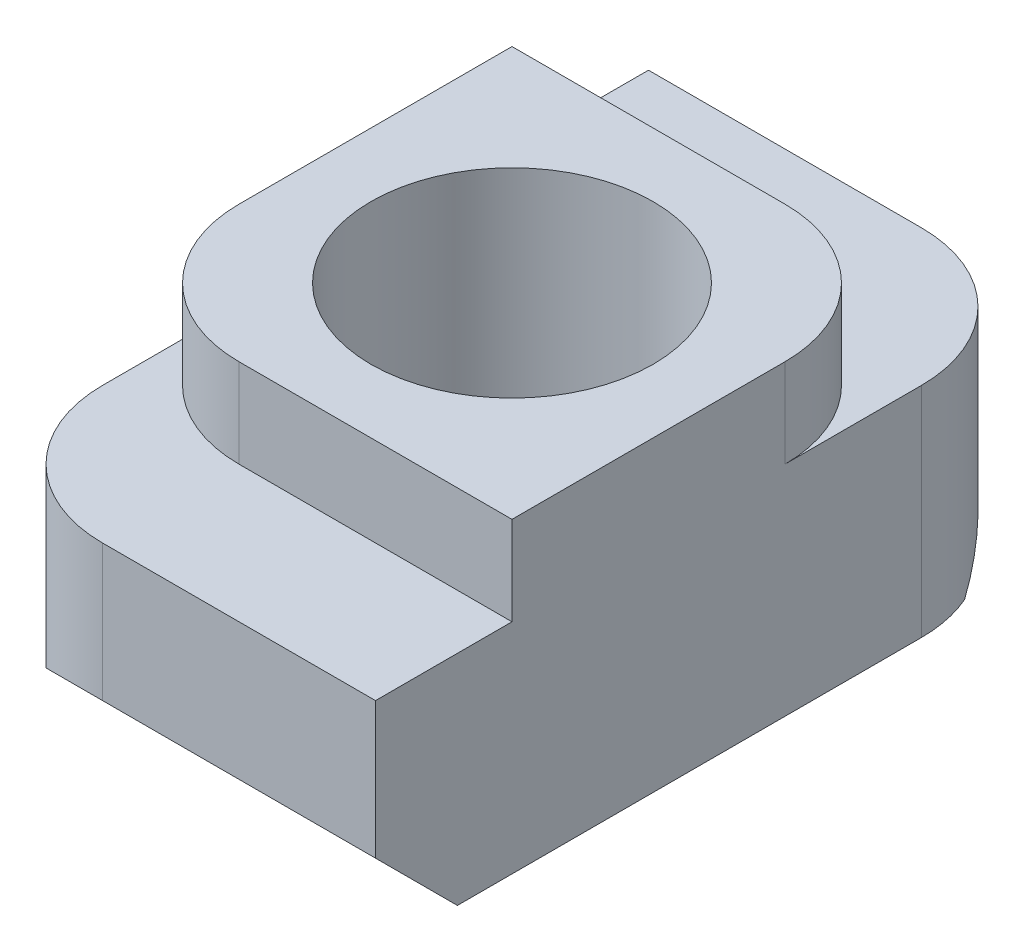
from build123d import *

# Parameters (mm, degrees)
BOSS_EXTRUDE1_DEPTH = 3
FILLET1_R           = 2
TAP1_D              = 4.134


with BuildPart() as part:
    # Sketch1 → Boss-Extrude1 (new body, symmetric)
    with BuildSketch(Plane(origin=(0, 0, 0), x_dir=(0, 0, -1), z_dir=(1, 0, 0))):
        Polygon((-3, 0), (3, 0), (3, -1.3), (5, -1.3), (5, -3.3), (3.8, -4.5), (-3.8, -4.5), (-5, -3.3), (-5, -1.3), (-3, -1.3), align=None)
    extrude(amount=BOSS_EXTRUDE1_DEPTH, both=True)

    # Fillet1
    fillet1_edges = [part.edges().sort_by_distance(p)[0] for p in [
        (3, -2.3, -5),
        (-3, -2.3, 5),
        (3, -0.65, -3),
        (-3, -0.65, 3),
    ]]
    fillet(fillet1_edges, radius=FILLET1_R)

    # Tap1 (through all)
    with Locations(Plane(origin=(0, 0, 0), x_dir=(1, 0, 0), z_dir=(0, 1, 0))):
        with Locations((0, 0)):
            Hole(TAP1_D / 2)


solid = part.part
